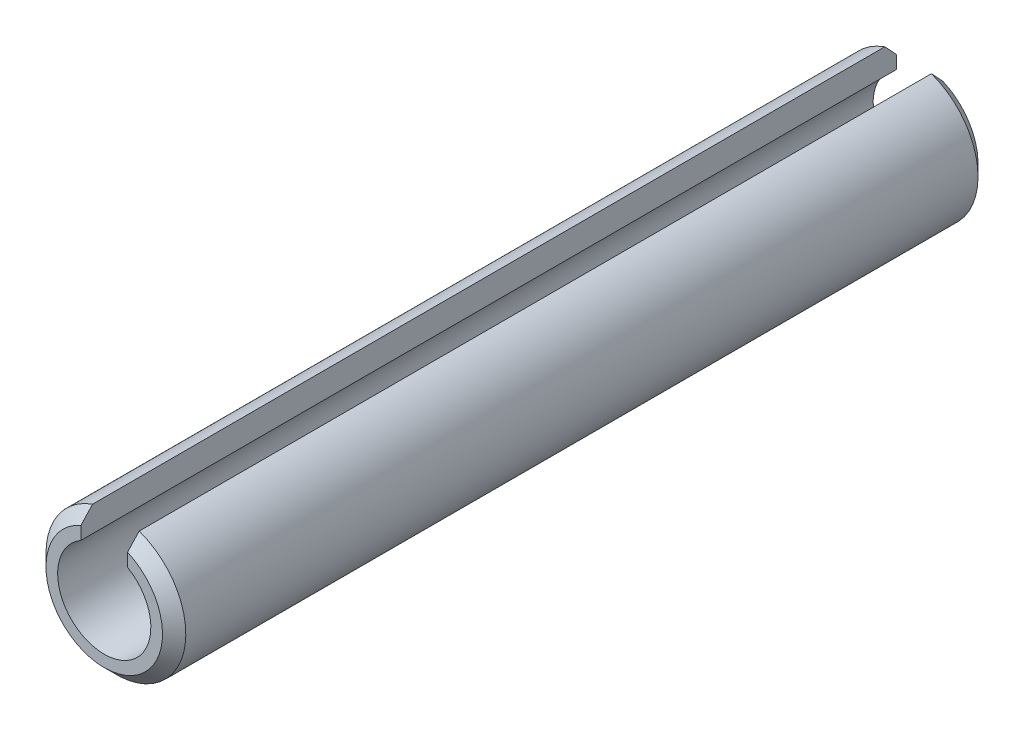
from build123d import *

# Parameters (mm, degrees)
EXTRUSION2_DEPTH = 35
CHANFREIN1_SIZE  = 0.5


with BuildPart() as part:
    # Esquisse1 → Extrusion2 (new body)
    with BuildSketch(Plane.XY):
        with BuildLine():
            Line((-1, 2.828427125), (-1, 1.732050808))
            ThreePointArc((-1, 1.732050808), (0, -2), (1, 1.732050808))
            Line((1, 1.732050808), (1, 2.828427125))
            ThreePointArc((1, 2.828427125), (0, -3), (-1, 2.828427125))
        make_face()
    extrude(amount=EXTRUSION2_DEPTH)

    # Chanfrein1
    chanfrein1_edges = [part.edges().sort_by_distance(p)[0] for p in [
        (0, -3, 35),
        (0, -3, 0),
    ]]
    chamfer(chanfrein1_edges, length=CHANFREIN1_SIZE)


solid = part.part
